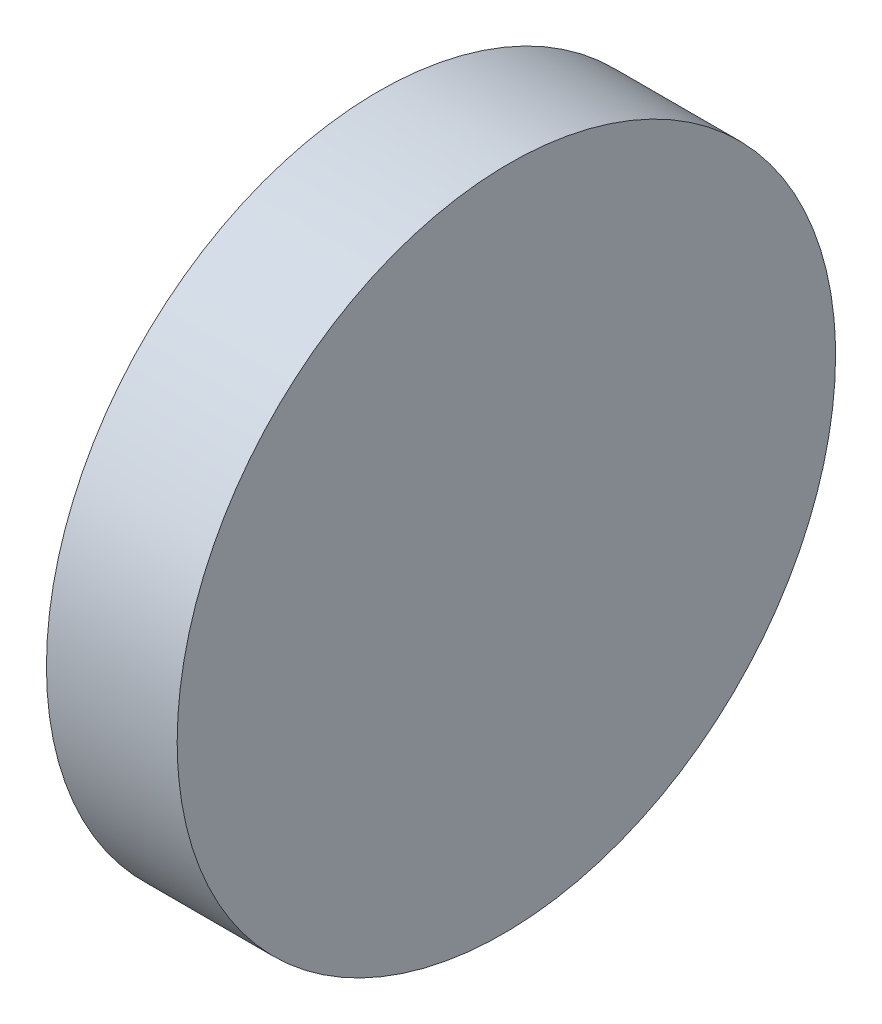
from build123d import *

# Parameters (mm, degrees)
EXTRUDE_1_DEPTH     = 25.4
CUT_EXTRUDE_2_DEPTH = 12.5


with BuildPart() as part:
    # 草图1 → 凸台-拉伸1 (new body)
    with BuildSketch(Plane(origin=(0, 0, 0), x_dir=(1, 0, 0), z_dir=(0, 1, 0))):
        Polygon((0, 12.7), (0, -12.7), (5, -12.7), (4.778337558, 12.7), align=None)
    extrude(amount=EXTRUDE_1_DEPTH)

    # 草图5 → 切除-拉伸2 (cut)
    with BuildSketch(Plane.ZY):
        with BuildLine():
            Line((-12.7, 25.4), (-12.7, 12.7))
            ThreePointArc((-12.7, 12.7), (-8.980256121, 21.680256121), (0, 25.4))
            Line((0, 25.4), (-12.7, 25.4))
        make_face()
        with BuildLine():
            Line((-12.7, 12.7), (-12.7, 0))
            Line((-12.7, 0), (0, 0))
            ThreePointArc((0, 0), (-8.980256121, 3.719743879), (-12.7, 12.7))
        make_face()
        with BuildLine():
            ThreePointArc((12.7, 12.7), (8.980256121, 3.719743879), (0, 0))
            Line((0, 0), (12.7, 0))
            Line((12.7, 0), (12.7, 12.7))
        make_face()
        with BuildLine():
            ThreePointArc((0, 25.4), (8.980256121, 21.680256121), (12.7, 12.7))
            Line((12.7, 12.7), (12.7, 25.4))
            Line((12.7, 25.4), (0, 25.4))
        make_face()
    extrude(amount=-CUT_EXTRUDE_2_DEPTH, mode=Mode.SUBTRACT)


solid = part.part
